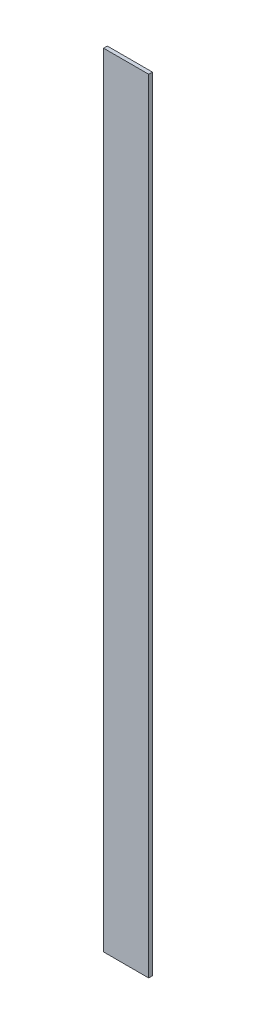
from build123d import *

# Parameters (mm, degrees)
SKETCH2_W           = 38.1
SKETCH2_H           = 3.175
BOSS_EXTRUDE1_DEPTH = 660.4


with BuildPart() as part:
    # Sketch2 → Boss-Extrude1 (new body)
    with BuildSketch(Plane(origin=(0, 0, 0), x_dir=(1, 0, 0), z_dir=(0, 1, 0))):
        with Locations((19.05, 1.5875)):
            Rectangle(SKETCH2_W, SKETCH2_H)
    extrude(amount=BOSS_EXTRUDE1_DEPTH)


solid = part.part
